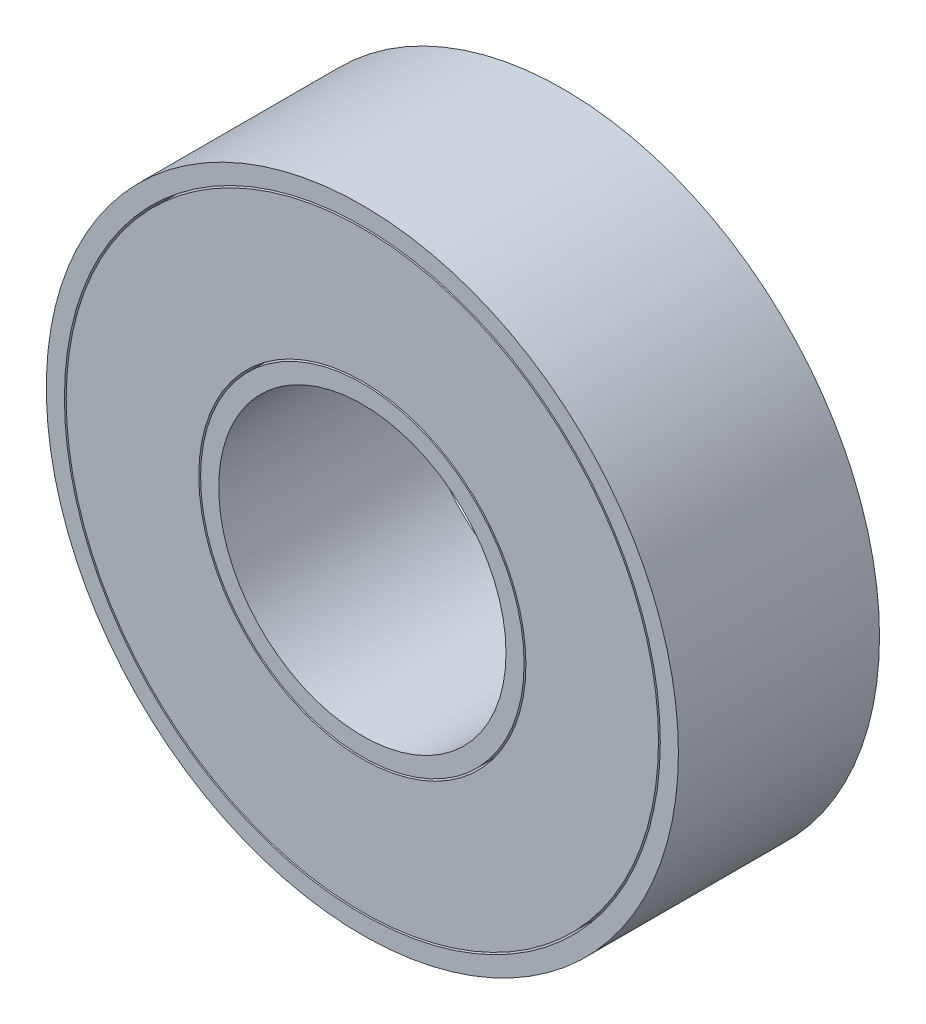
from build123d import *

# Parameters (mm, degrees)
CROQUIS1_R              = 17.4625
CROQUIS1_R_2            = 7.9375
SALIENTE_EXTRUIR1_DEPTH = 11.112
CROQUIS5_R              = 16.4625
CROQUIS5_R_2            = 16.3625
CROQUIS5_R_3            = 9.0375
CROQUIS5_R_4            = 8.9375
CORTAR_EXTRUIR4_DEPTH   = 20.5


with BuildPart() as part:
    # Croquis1 → Saliente-Extruir1 (new body)
    with BuildSketch(Plane.XY):
        Circle(CROQUIS1_R)
        Circle(CROQUIS1_R_2, mode=Mode.SUBTRACT)
    extrude(amount=SALIENTE_EXTRUIR1_DEPTH)

    # Croquis5 → Cortar-Extruir4 (cut)
    with BuildSketch(Plane(origin=(0, 0, 0), x_dir=(-1, 0, 0), z_dir=(0, 0, -1))):
        Circle(CROQUIS5_R)
        Circle(CROQUIS5_R_2, mode=Mode.SUBTRACT)
        Circle(CROQUIS5_R_3)
        Circle(CROQUIS5_R_4, mode=Mode.SUBTRACT)
    extrude(amount=-CORTAR_EXTRUIR4_DEPTH, mode=Mode.SUBTRACT)


with BuildPart() as cortar_extruir4_piece_1:
    # of the separate pieces the step leaves, piece 1, a body of its own (cortar_extruir4_pieces)
    add(part.part.solids().sort_by_distance((-16.3625, 0, 0))[0])


with BuildPart() as cortar_extruir4_piece_2:
    # of the separate pieces the step leaves, piece 2, a body of its own (cortar_extruir4_pieces)
    add(part.part.solids().sort_by_distance((17.4625, 0, 0))[0])


with BuildPart() as cortar_extruir4_piece_3:
    # of the separate pieces the step leaves, piece 3, a body of its own (cortar_extruir4_pieces)
    add(part.part.solids().sort_by_distance((-8.9375, 0, 0))[0])


solid = Compound([cortar_extruir4_piece_1.part, cortar_extruir4_piece_2.part, cortar_extruir4_piece_3.part])
